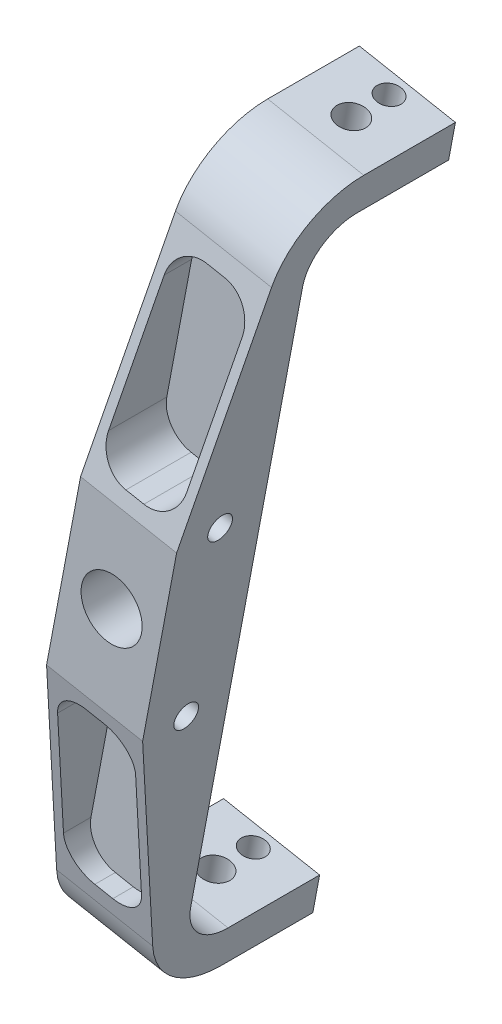
from build123d import *

# Parameters (mm, degrees)
SKETCH1_R               = 10
BOSS_EXTRUDE1_DEPTH     = 28.5
BOSS_EXTRUDE2_DEPTH     = 45
SKETCH4_R               = 4.7625
SKETCH4_R_2             = 3.96875
CUT_EXTRUDE1_DEPTH      = 258.595725096
FILLET3_R               = 15
SKETCH10_R              = 4
CUT_EXTRUDE2_DEPTH      = 78.869968284
CUT_EXTRUDE2_DEPTH_BACK = 46.869968284
CUT_EXTRUDE4_DEPTH      = 22.5


with BuildPart() as part:
    # Sketch1 → Boss-Extrude1 (new body)
    with BuildSketch(Plane.XY):
        Polygon((-7.617068705, -126.66669812), (39.062241625, 120.733646626), (7.617068705, 126.66669812), (-39.062241625, -120.733646626), align=None)
        Circle(SKETCH1_R, mode=Mode.SUBTRACT)
    extrude(amount=BOSS_EXTRUDE1_DEPTH)

    # Sketch2 → Boss-Extrude2 (add)
    with BuildSketch(Plane(origin=(0, 0, 0), x_dir=(-1, 0, 0), z_dir=(0, 0, -1))):
        Polygon((-39.062241625, 120.733646626), (-36.837347314, 108.941706781), (-5.392174394, 114.874758275), (-7.617068705, 126.66669812), align=None)
        Polygon((36.837347314, -108.941706781), (5.392174394, -114.874758275), (7.617068705, -126.66669812), (39.062241625, -120.733646626), align=None)
    extrude(amount=BOSS_EXTRUDE2_DEPTH)

    # Sketch4 → Cut-Extrude1 (cut, through all)
    with BuildSketch(Plane(origin=(-1.656161502, 128.416364197, 0), x_dir=(0.982661654, -0.185407859, 0), z_dir=(0.185407859, 0.982661654, 0))):
        with Locations((25.436849572, 26.64759704)):
            Circle(SKETCH4_R)
        with Locations((25.436849572, 39)):
            Circle(SKETCH4_R_2)
    extrude(amount=-CUT_EXTRUDE1_DEPTH, mode=Mode.SUBTRACT)

    # Fillet3
    fillet3_edges = [part.edges().sort_by_distance(p)[0] for p in [
        (21.114760854, 111.908232528, 0),
        (-21.114760854, -111.908232528, 0),
    ]]
    fillet(fillet3_edges, radius=FILLET3_R)

    # Sketch10 → Cut-Extrude2 (cut, two sides)
    with BuildSketch(Plane(origin=(-16.024269994, 1.367603019, 0), x_dir=(0, 0, -1), z_dir=(0.982661654, -0.185407859, 0))) as cut_extrude2_sk:
        with Locations((-14.25, 31.627134551)):
            Circle(SKETCH10_R)
        with Locations((-14.25, -28.372865449)):
            Circle(SKETCH10_R)
        with BuildLine():
            Line((-28.5, 31.627134551), (-11.316666773, 106.545885621))
            ThreePointArc((-11.316666773, 106.545885621), (-1.82302812, 121.628280107), (15, 127.509906002))
            Line((15, 127.509906002), (-44.768549469, 140.171550448))
            Line((-44.768549469, 140.171550448), (-46.912682998, 31.416920937))
            Line((-46.912682998, 31.416920937), (-28.5, 31.627134551))
        make_face()
        with BuildLine():
            Line((-44.768549469, -136.917281346), (15, -124.255636901))
            ThreePointArc((15, -124.255636901), (-1.82302812, -118.374011006), (-11.316666773, -103.29161652))
            Line((-11.316666773, -103.29161652), (-28.5, -28.372865449))
            Line((-28.5, -28.372865449), (-46.912682998, -28.162651835))
            Line((-46.912682998, -28.162651835), (-44.768549469, -136.917281346))
        make_face()
    extrude(amount=CUT_EXTRUDE2_DEPTH, mode=Mode.SUBTRACT)
    extrude(cut_extrude2_sk.sketch, amount=-CUT_EXTRUDE2_DEPTH_BACK, mode=Mode.SUBTRACT)

    # Sketch11 → Cut-Extrude4 (cut)
    with BuildSketch(Plane.XY.offset(28.5)):
        with BuildLine():
            Line((3.541290111, 34.949381459), (9.437260033, 33.836934304))
            ThreePointArc((9.437260033, 33.836934304), (16.92877427, 35.404052106), (21.117955163, 41.809472249))
            Line((21.117955163, 41.809472249), (29.254165873, 84.931389014))
            ThreePointArc((29.254165873, 84.931389014), (27.687048071, 92.422903251), (21.281627928, 96.612084144))
            Line((21.281627928, 96.612084144), (15.385658005, 97.724531299))
            ThreePointArc((15.385658005, 97.724531299), (7.894143769, 96.157413497), (3.704962876, 89.751993354))
            Line((3.704962876, 89.751993354), (-4.431247835, 46.630076588))
            ThreePointArc((-4.431247835, 46.630076588), (-2.864130032, 39.138562352), (3.541290111, 34.949381459))
        make_face()
        with BuildLine():
            Line((-21.281627928, -96.612084144), (-15.385658005, -97.724531299))
            ThreePointArc((-15.385658005, -97.724531299), (-7.894143769, -96.157413497), (-3.704962876, -89.751993354))
            Line((-3.704962876, -89.751993354), (4.431247835, -46.630076588))
            ThreePointArc((4.431247835, -46.630076588), (2.864130032, -39.138562352), (-3.541290111, -34.949381459))
            Line((-3.541290111, -34.949381459), (-9.437260033, -33.836934304))
            ThreePointArc((-9.437260033, -33.836934304), (-16.92877427, -35.404052106), (-21.117955163, -41.809472249))
            Line((-21.117955163, -41.809472249), (-29.254165873, -84.931389014))
            ThreePointArc((-29.254165873, -84.931389014), (-27.687048071, -92.422903251), (-21.281627928, -96.612084144))
        make_face()
    extrude(amount=-CUT_EXTRUDE4_DEPTH, mode=Mode.SUBTRACT)


solid = part.part
